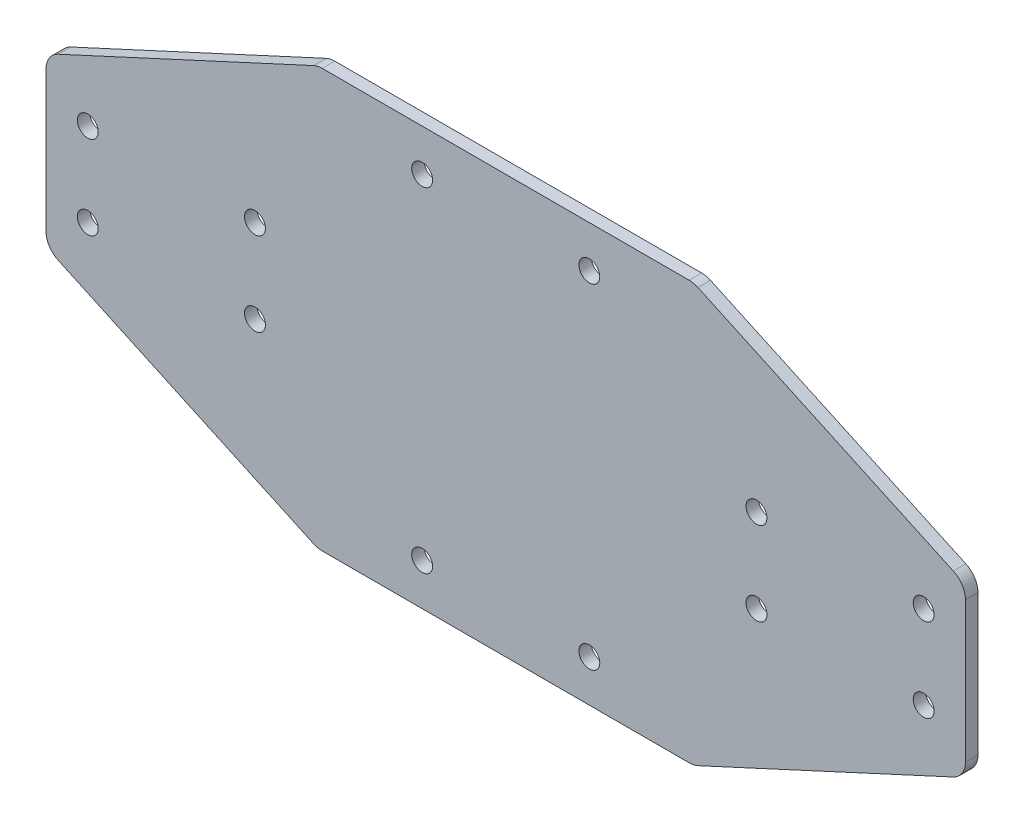
from build123d import *

# Parameters (mm, degrees)
BOSS_EXTRUDE1_DEPTH     = 3
SKETCH2_R               = 2.5
CUT_EXTRUDE1_DEPTH      = 4
LPATTERN1_COUNT         = 2
LPATTERN1_PITCH         = 40
LPATTERN1_COUNT_DIR2    = 2
LPATTERN1_PITCH_DIR2    = 20
MIRROR1_COPY_1_SKETCH_R = 2.5
MIRROR1_COPY_1_DEPTH    = 4
MIRROR1_COPY_2_SKETCH_R = 2.5
MIRROR1_COPY_2_DEPTH    = 4
MIRROR1_COPY_3_SKETCH_R = 2.5
MIRROR1_COPY_3_DEPTH    = 4
SKETCH3_R               = 2.5
CUT_EXTRUDE2_DEPTH      = 4
FILLET1_R               = 5


with BuildPart() as part:
    # Sketch1 → Boss-Extrude1 (new body)
    with BuildSketch(Plane.XY):
        Polygon((-110, 20), (-110, -20), (-45, -50), (45, -50), (110, -20), (110, 20), (45, 50), (-45, 50), align=None)
    extrude(amount=BOSS_EXTRUDE1_DEPTH)

    # Sketch2 → Cut-Extrude1 (cut, through all)
    with BuildSketch(Plane.XY.offset(3)):
        with Locations((60, 10)):
            Circle(SKETCH2_R)
    cut_extrude1 = extrude(amount=-CUT_EXTRUDE1_DEPTH, mode=Mode.SUBTRACT)

    # LPattern1: Cut-Extrude1 2 × 2
    with Locations(*[(i * LPATTERN1_PITCH, -j * LPATTERN1_PITCH_DIR2, 0) for i in range(LPATTERN1_COUNT) for j in range(LPATTERN1_COUNT_DIR2) if (i, j) != (0, 0)]):
        add(cut_extrude1, mode=Mode.SUBTRACT)

    # Mirror1: Cut-Extrude1 across plane
    add(cut_extrude1.mirror(Plane(origin=(0, 0, 0), x_dir=(0, 0, 1), z_dir=(1, 0, 0))), mode=Mode.SUBTRACT)

    # Mirror1 copy 1 sketch → Mirror1 copy 1 (cut, through all)
    with BuildSketch(Plane(origin=(0, -20, 3), x_dir=(-1, 0, 0), z_dir=(0, 0, 1))):
        with Locations((60, -10)):
            Circle(MIRROR1_COPY_1_SKETCH_R)
    extrude(amount=-MIRROR1_COPY_1_DEPTH, mode=Mode.SUBTRACT)

    # Mirror1 copy 2 sketch → Mirror1 copy 2 (cut, through all)
    with BuildSketch(Plane(origin=(-40, 0, 3), x_dir=(-1, 0, 0), z_dir=(0, 0, 1))):
        with Locations((60, -10)):
            Circle(MIRROR1_COPY_2_SKETCH_R)
    extrude(amount=-MIRROR1_COPY_2_DEPTH, mode=Mode.SUBTRACT)

    # Mirror1 copy 3 sketch → Mirror1 copy 3 (cut, through all)
    with BuildSketch(Plane(origin=(-40, -20, 3), x_dir=(-1, 0, 0), z_dir=(0, 0, 1))):
        with Locations((60, -10)):
            Circle(MIRROR1_COPY_3_SKETCH_R)
    extrude(amount=-MIRROR1_COPY_3_DEPTH, mode=Mode.SUBTRACT)

    # Sketch3 → Cut-Extrude2 (cut, through all)
    with BuildSketch(Plane.XY.offset(3)):
        with Locations((20, 40)):
            Circle(SKETCH3_R)
        with Locations((-20, 40)):
            Circle(SKETCH3_R)
    cut_extrude2 = extrude(amount=-CUT_EXTRUDE2_DEPTH, mode=Mode.SUBTRACT)

    # Mirror2: Cut-Extrude2 across plane
    add(cut_extrude2.mirror(Plane.ZX), mode=Mode.SUBTRACT)

    # Fillet1
    fillet1_edges = [part.edges().sort_by_distance(p)[0] for p in [
        (-45, 50, 1.5),
        (45, 50, 1.5),
        (110, 20, 1.5),
        (110, -20, 1.5),
        (45, -50, 1.5),
        (-45, -50, 1.5),
        (-110, -20, 1.5),
        (-110, 20, 1.5),
    ]]
    fillet(fillet1_edges, radius=FILLET1_R)


solid = part.part
